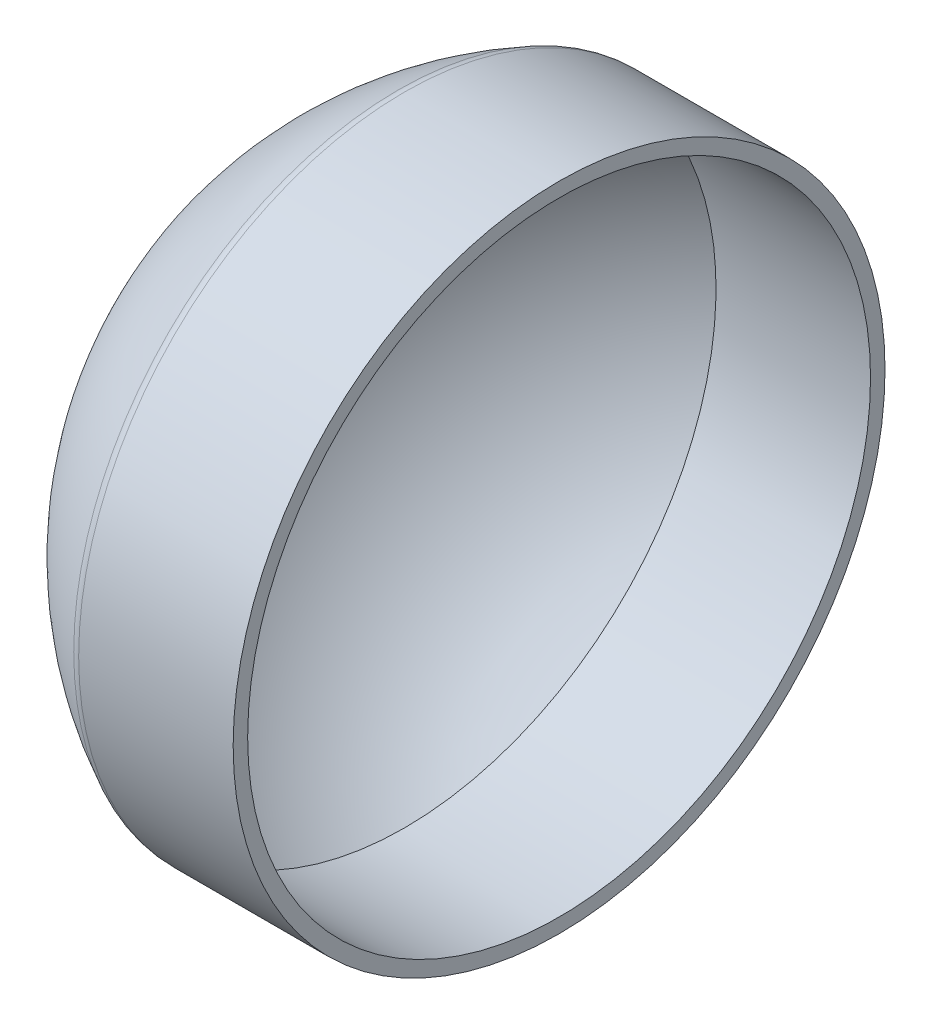
from build123d import *

# Parameters (mm, degrees)
FILLET1_R = 25.4


with BuildPart() as part:
    # Sketch1 → Revolve3 (revolve)
    with BuildSketch(Plane.XY):
        with BuildLine():
            Line((317.500635001, 571.501143002), (40.709998505, 571.501143002))
            ThreePointArc((40.709998505, 571.501143002), (-220.546304682, 337.241906652), (-317.500635001, 0))
            Line((-317.500635001, 0), (-292.100584201, 0))
            ThreePointArc((-292.100584201, 0), (-200.551053799, 321.303741317), (46.599834802, 546.101092202))
            Line((46.599834802, 546.101092202), (317.500635001, 546.101092202))
            Line((317.500635001, 546.101092202), (317.500635001, 571.501143002))
        make_face()
    revolve(axis=Axis((-317.500635001, 0, 0), (1, 0, 0)))

    # Fillet1
    fillet1_edges = [part.edges().sort_by_distance(p)[0] for p in [
        (40.709998505, -571.501143002, 0),
    ]]
    fillet(fillet1_edges, radius=FILLET1_R)


solid = part.part
